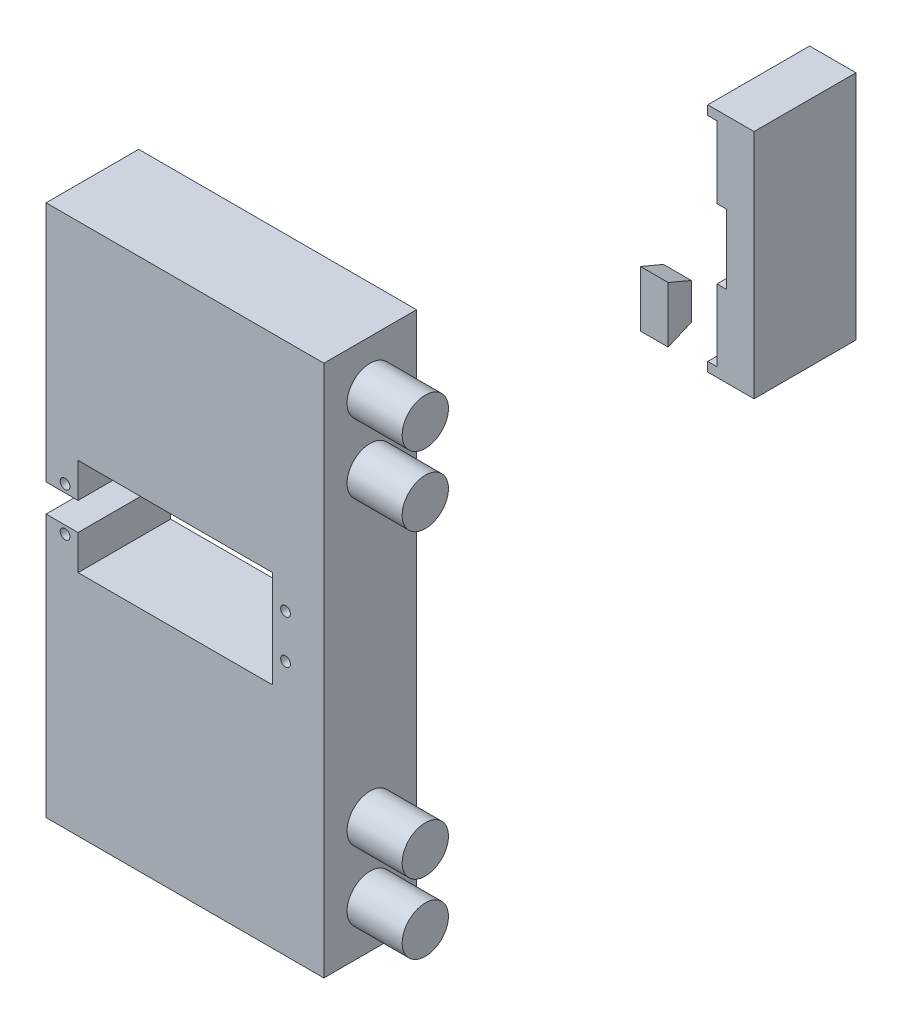
from build123d import *

# Parameters (mm, degrees)
SKETCH_5_W           = 60
SKETCH_5_H           = 115
EXTRUDE_2_DEPTH      = 20
SKETCH_1_R           = 1.05
CUT_EXTRUDE_4_DEPTH  = 20
SKETCH_6_R           = 5
EXTRUDE_3_DEPTH      = 12
EXTRUDE_6_DEPTH      = 6
EXTRUDE_6_DEPTH_BACK = 4
SKETCH_13_W          = 22
SKETCH_13_H          = 50
SKETCH_16_W          = 20
SKETCH_16_H          = 46
CUT_EXTRUDE_9_DEPTH  = 2
SKETCH_17_W          = 5
SKETCH_17_H          = 15
CUT_EXTRUDE_10_DEPTH = 4
EXTRUDE_7_DEPTH      = 6


with BuildPart() as part:
    # 草圖5 → 填料-伸長2 (new body)
    with BuildSketch(Plane.XY):
        with Locations((85.095319229, -5.277137892)):
            Rectangle(SKETCH_5_W, SKETCH_5_H)
    extrude(amount=EXTRUDE_2_DEPTH)

    # 草圖1 → 除料-伸長4 (cut)
    with BuildSketch(Plane.XY):
        with Locations((59.19, 1.7)):
            Circle(SKETCH_1_R)
        with Locations((106.81, 1.7)):
            Circle(SKETCH_1_R)
        with Locations((106.81, -7.7)):
            Circle(SKETCH_1_R)
        with Locations((59.19, -7.7)):
            Circle(SKETCH_1_R)
        Polygon((55, -3), (55, 0), (62, 0), (62, 7.5), (104, 7.5), (104, -13.5), (62, -13.5), (62, -6), (55, -6), align=None)
    extrude(amount=CUT_EXTRUDE_4_DEPTH, mode=Mode.SUBTRACT)

    # 草圖6 → 填料-伸長3 (add)
    with BuildSketch(Plane(origin=(115, 0, 0), x_dir=(0, 0, -1), z_dir=(1, 0, 0))):
        with Locations((-10, 42.222862108)):
            Circle(SKETCH_6_R)
        with Locations((-10, 27.222862108)):
            Circle(SKETCH_6_R)
        with Locations((-10, -37.777137892)):
            Circle(SKETCH_6_R)
        with Locations((-10, -52.777137892)):
            Circle(SKETCH_6_R)
    extrude(amount=EXTRUDE_3_DEPTH)


with BuildPart() as body_2:
    # 草圖13 → 填料-伸長6 (new, two sides: drawn at the far end of the back side and taken through both)
    with BuildSketch(Plane(origin=(82, 0, 0), x_dir=(0, 0, -1), z_dir=(1, 0, 0)).offset(-EXTRUDE_6_DEPTH_BACK)):
        with Locations((111, -3)):
            Rectangle(SKETCH_13_W, SKETCH_13_H)
    extrude(amount=EXTRUDE_6_DEPTH + EXTRUDE_6_DEPTH_BACK)

    # 草圖16 → 除料-伸長9 (cut)
    with BuildSketch(Plane(origin=(78, 0, 0), x_dir=(0, 0, -1), z_dir=(1, 0, 0))):
        with Locations((110, -3)):
            Rectangle(SKETCH_16_W, SKETCH_16_H)
    extrude(amount=CUT_EXTRUDE_9_DEPTH, mode=Mode.SUBTRACT)

    # 草圖17 → 除料-伸長10 (cut)
    with BuildSketch(Plane(origin=(78, 0, 0), x_dir=(0, 0, -1), z_dir=(1, 0, 0))):
        with Locations((102.5, -3)):
            Rectangle(SKETCH_17_W, SKETCH_17_H)
    extrude(amount=CUT_EXTRUDE_10_DEPTH, mode=Mode.SUBTRACT)


with BuildPart() as body_3:
    # 草圖18 → 填料-伸長7 (new body)
    with BuildSketch(Plane(origin=(82, 0, 0), x_dir=(0, 0, -1), z_dir=(1, 0, 0))):
        Polygon((86.437354092, 0.930152969), (86.437354092, -6.930152969), (81.441973623, -9.043594565), (81.441973623, 3.043594565), align=None)
    extrude(amount=EXTRUDE_7_DEPTH)


solid = Compound([part.part, body_2.part, body_3.part])
